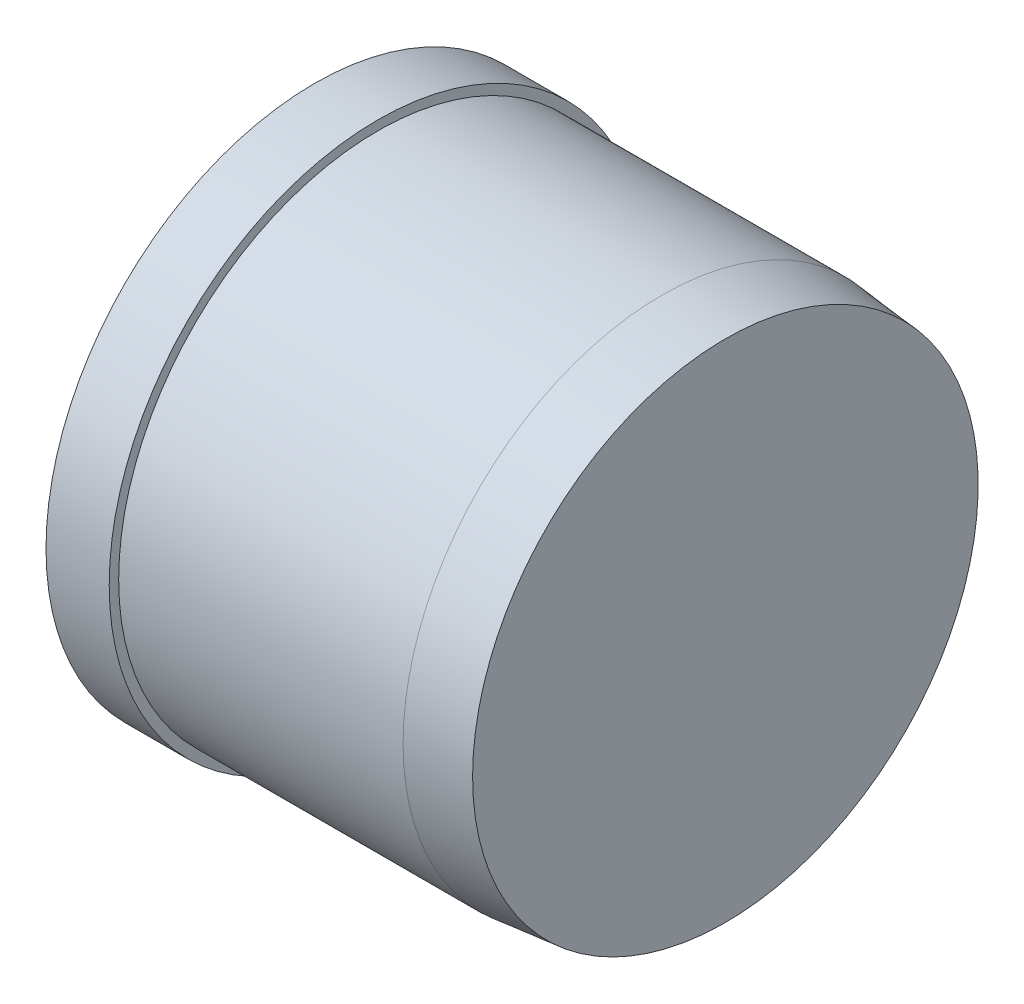
from build123d import *


with BuildPart() as part:
    # Sketch1 → Revolve1 (revolve)
    with BuildSketch(Plane.XY):
        Polygon((65, 0), (65, 40), (55, 41), (10, 41), (10, 42.5), (0, 42.5), (0, 0), align=None)
    revolve(axis=Axis((0, 0, 0), (1, 0, 0)))


solid = part.part
